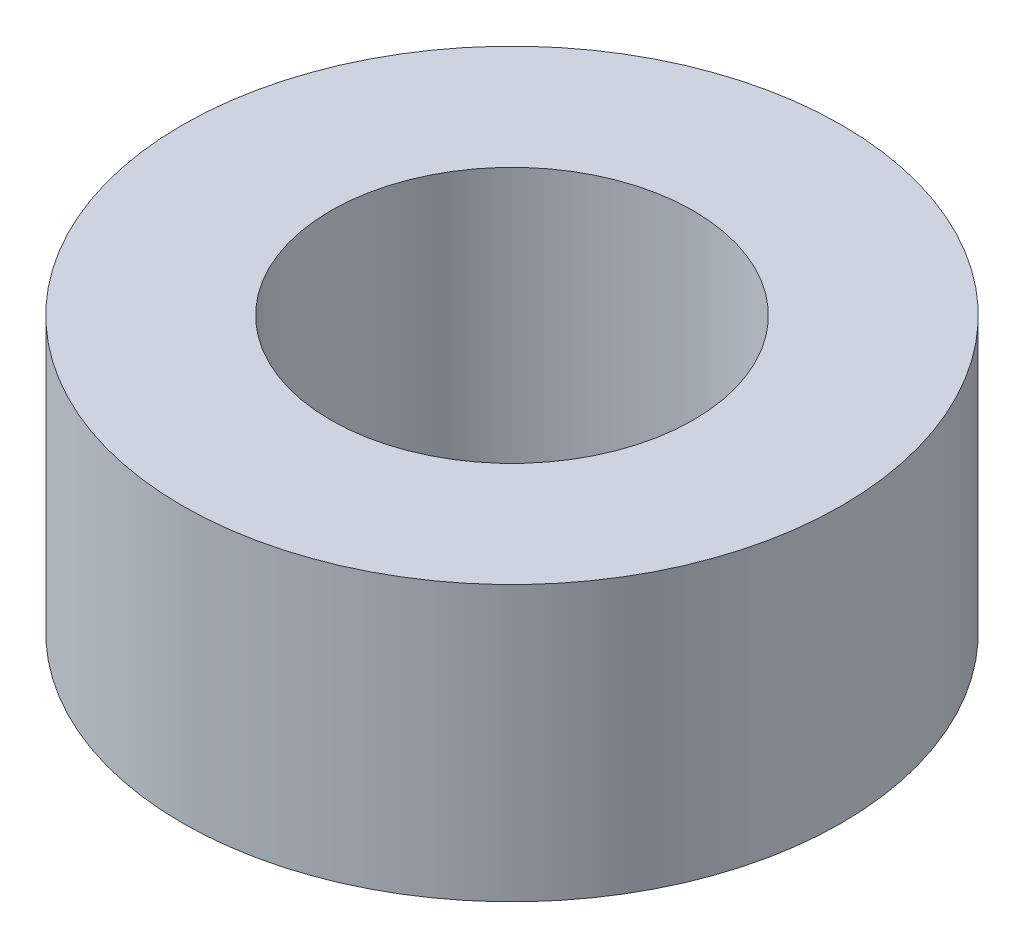
from build123d import *

# Parameters (mm, degrees)
SKETCH1_R           = 6
SKETCH1_R_2         = 3.3
BOSS_EXTRUDE1_DEPTH = 5


with BuildPart() as part:
    # Sketch1 → Boss-Extrude1 (new body)
    with BuildSketch(Plane(origin=(0, 0, 0), x_dir=(1, 0, 0), z_dir=(0, 1, 0))):
        Circle(SKETCH1_R)
        Circle(SKETCH1_R_2, mode=Mode.SUBTRACT)
    extrude(amount=BOSS_EXTRUDE1_DEPTH)


solid = part.part
